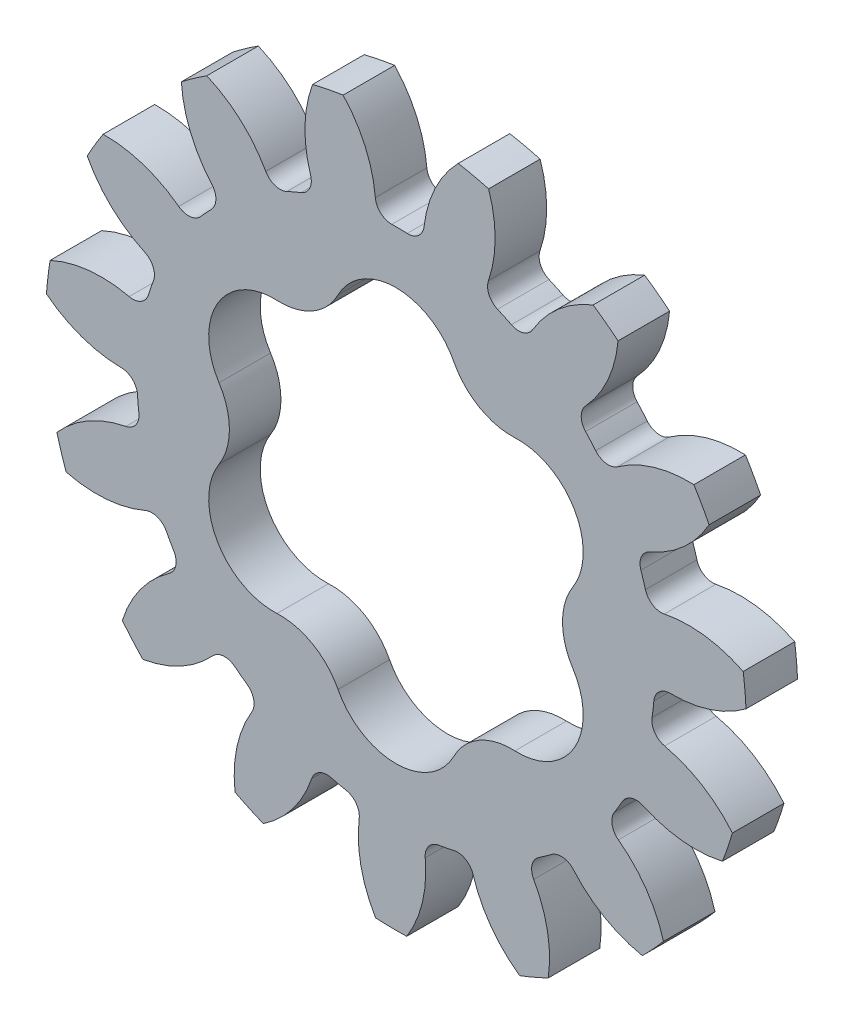
from build123d import *

# Parameters (mm, degrees)
SKETCH3_R          = 21.59
GEARBODY_DEPTH     = 3.175
TOOTHCUT_DEPTH     = 31.697505192
CIRPATTERN1_COUNT  = 15
BOREDIA_R          = 1.499997014
BORE_DEPTH         = 12700
CUT_EXTRUDE1_DEPTH = 31.681055895


with BuildPart() as part:
    # Sketch3 → gearBody (new body)
    with BuildSketch(Plane.XY):
        Circle(SKETCH3_R)
    extrude(amount=GEARBODY_DEPTH)

    # Sketch2 → toothCut (cut, through all)
    with BuildSketch(Plane.XY):
        with BuildLine():
            ThreePointArc((15.776737466, -2.352729556), (15.839461945, -1.88473519), (15.888307135, -1.41508933))
            ThreePointArc((15.888307135, -1.41508933), (16.217352653, -0.757105225), (16.906558448, -0.499793338))
            ThreePointArc((16.906558448, -0.499793338), (20.511887209, 0.343917978), (23.283949955, 2.798691365))
            ThreePointArc((23.283949955, 2.798691365), (23.287267838, -2.770948491), (21.977086037, -8.184295218))
            ThreePointArc((21.977086037, -8.184295218), (19.858454824, -5.147578893), (16.551776463, -3.481408892))
            ThreePointArc((16.551776463, -3.481408892), (15.942194667, -3.069554465), (15.776737466, -2.352729556))
        make_face()
    toothcut = extrude(amount=TOOTHCUT_DEPTH, mode=Mode.SUBTRACT)

    # CirPattern1: toothCut ×15 about axis
    cirpattern1_axis = Axis((0, 0, 3.175), (0, 0, -1))
    for i in range(1, CIRPATTERN1_COUNT):
        add(toothcut.rotate(cirpattern1_axis, i * 360 / CIRPATTERN1_COUNT), mode=Mode.SUBTRACT)

    # boreDia → bore (cut, symmetric)
    with BuildSketch(Plane.XY):
        Circle(BOREDIA_R)
    extrude(amount=BORE_DEPTH, both=True, mode=Mode.SUBTRACT)

    # Sketch4 → Cut-Extrude1 (cut, through all)
    with BuildSketch(Plane(origin=(0, 0, 0), x_dir=(-1, 0, 0), z_dir=(0, 0, -1))):
        with BuildLine():
            ThreePointArc((-7.329682086, 8.352449747), (-5.130117272, 8.885623765), (-3.568592622, 10.523915761))
            ThreePointArc((-3.568592622, 10.523915761), (0, 12.7), (3.568592622, 10.523915761))
            ThreePointArc((3.568592622, 10.523915761), (5.130117272, 8.885623765), (7.329682086, 8.352449747))
            ThreePointArc((7.329682086, 8.352449747), (10.998522628, 6.35), (10.898274707, 2.171466014))
            ThreePointArc((10.898274707, 2.171466014), (10.260234545, 0), (10.898274707, -2.171466014))
            ThreePointArc((10.898274707, -2.171466014), (10.998522628, -6.35), (7.329682086, -8.352449747))
            ThreePointArc((7.329682086, -8.352449747), (5.130117272, -8.885623765), (3.568592622, -10.523915761))
            ThreePointArc((3.568592622, -10.523915761), (0, -12.7), (-3.568592622, -10.523915761))
            ThreePointArc((-3.568592622, -10.523915761), (-5.130117272, -8.885623765), (-7.329682086, -8.352449747))
            ThreePointArc((-7.329682086, -8.352449747), (-10.998522628, -6.35), (-10.898274707, -2.171466014))
            ThreePointArc((-10.898274707, -2.171466014), (-10.260234545, 0), (-10.898274707, 2.171466014))
            ThreePointArc((-10.898274707, 2.171466014), (-10.998522628, 6.35), (-7.329682086, 8.352449747))
        make_face()
    extrude(amount=-CUT_EXTRUDE1_DEPTH, mode=Mode.SUBTRACT)


solid = part.part
